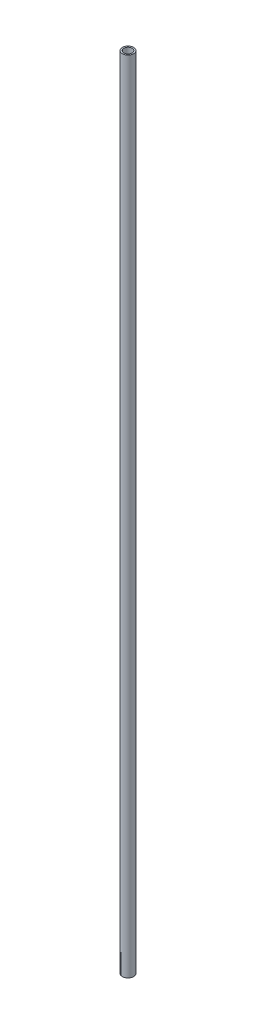
from build123d import *

# Parameters (mm, degrees)
SKETCH1_R           = 10.668
SKETCH1_R_2         = 7.8994
BOSS_EXTRUDE1_DEPTH = 1524


with BuildPart() as part:
    # Sketch1 → Boss-Extrude1 (new body)
    with BuildSketch(Plane(origin=(0, 0, 0), x_dir=(1, 0, 0), z_dir=(0, 1, 0))):
        Circle(SKETCH1_R)
        Circle(SKETCH1_R_2, mode=Mode.SUBTRACT)
    extrude(amount=BOSS_EXTRUDE1_DEPTH)


solid = part.part
